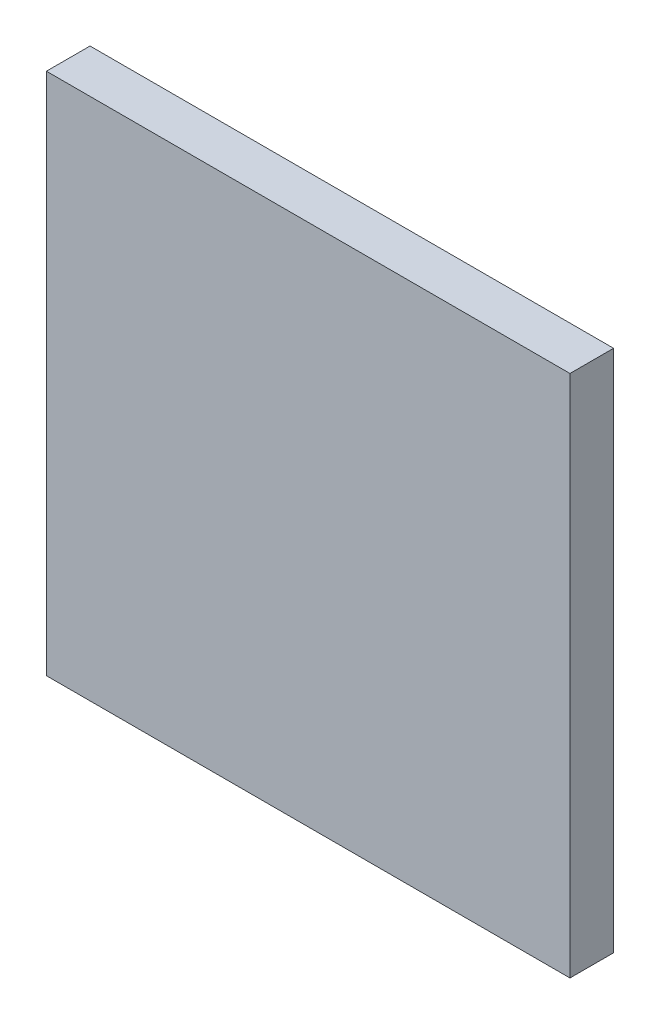
from build123d import *

# Parameters (mm, degrees)
SKETCH1_W           = 30
SKETCH1_H           = 30
BOSS_EXTRUDE1_DEPTH = 2.5


with BuildPart() as part:
    # Sketch1 → Boss-Extrude1 (new body)
    with BuildSketch(Plane.XY):
        with Locations((15, 15)):
            Rectangle(SKETCH1_W, SKETCH1_H)
    extrude(amount=BOSS_EXTRUDE1_DEPTH)


solid = part.part
